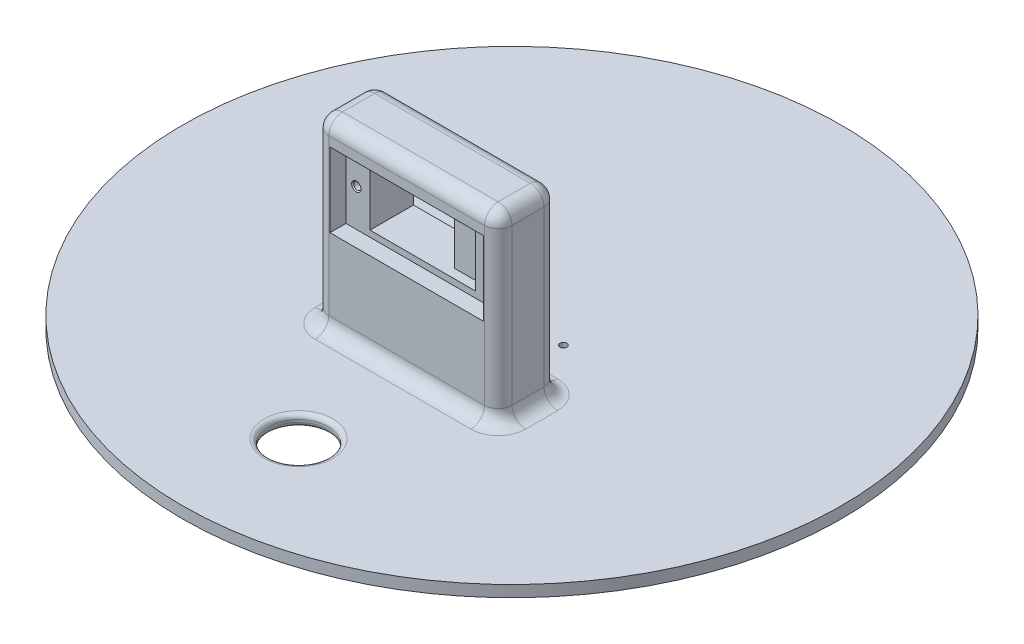
from build123d import *

# Parameters (mm, degrees)
SKETCH1_R                       = 72
BOSS_EXTRUDE1_DEPTH             = 2.5
SKETCH2_R                       = 0.75
CUT_EXTRUDE1_DEPTH              = 2.5
SKETCH5_W                       = 40
SKETCH5_H                       = 18
BOSS_EXTRUDE3_DEPTH             = 40
SKETCH6_W                       = 33.5
SKETCH6_H                       = 16.220064856
CUT_EXTRUDE2_DEPTH              = 3.5
SKETCH7_W                       = 23
SKETCH7_H                       = 16.220064856
CUT_EXTRUDE3_DEPTH              = 2
SKETCH8_W                       = 16.5
SKETCH8_H                       = 16.220064856
CUT_EXTRUDE4_DEPTH              = 7
SKETCH9_W                       = 5
SKETCH9_H                       = 40
CUT_EXTRUDE5_DEPTH              = 93
SKETCH10_W                      = 16.5
SKETCH10_H                      = 16.220064856
CUT_EXTRUDE6_DEPTH              = 83.5
SKETCH13_W                      = 33.5
SKETCH13_H                      = 1.36
BOSS_EXTRUDE4_DEPTH             = 9.5
M2X0_4_TAPPED_HOLE1_D           = 1.6
M2X0_4_TAPPED_HOLE1_DEPTH       = 6
M2X0_4_TAPPED_HOLE1_CSINK_D     = 2.05
M2X0_4_TAPPED_HOLE1_CSINK_ANGLE = 90
M2X0_4_TAPPED_HOLE1_TIP         = 0.480688495
FILLET1_R                       = 3
FILLET2_R                       = 3
FILLET3_R                       = 3
SKETCH16_R                      = 6.5
CUT_EXTRUDE7_DEPTH              = 3.5
FILLET4_R                       = 1
SKETCH17_R                      = 0.75
CUT_EXTRUDE8_DEPTH              = 3.5


with BuildPart() as part:
    # Sketch1 → Boss-Extrude1 (new body)
    with BuildSketch(Plane(origin=(0, 0, 0), x_dir=(1, 0, 0), z_dir=(0, 1, 0))):
        Circle(SKETCH1_R)
    extrude(amount=BOSS_EXTRUDE1_DEPTH)

    # Sketch2 → Cut-Extrude1 (cut)
    with BuildSketch(Plane(origin=(0, 0, 0), x_dir=(-1, 0, 0), z_dir=(0, -1, 0))):
        with Locations((-11.25, 0)):
            Circle(SKETCH2_R)
        with Locations((11.25, 0)):
            Circle(SKETCH2_R)
    extrude(amount=-CUT_EXTRUDE1_DEPTH, mode=Mode.SUBTRACT)

    # Sketch5 → Boss-Extrude3 (add)
    with BuildSketch(Plane(origin=(0, 2.5, 0), x_dir=(1, 0, 0), z_dir=(0, 1, 0))):
        with Locations((0, -14)):
            Rectangle(SKETCH5_W, SKETCH5_H)
    extrude(amount=BOSS_EXTRUDE3_DEPTH)

    # Sketch6 → Cut-Extrude2 (cut)
    with BuildSketch(Plane.XY.offset(23)):
        with Locations((0, 29.389629851)):
            Rectangle(SKETCH6_W, SKETCH6_H)
    extrude(amount=-CUT_EXTRUDE2_DEPTH, mode=Mode.SUBTRACT)

    # Sketch7 → Cut-Extrude3 (cut)
    with BuildSketch(Plane.XY.offset(19.5)):
        with Locations((0, 29.389629851)):
            Rectangle(SKETCH7_W, SKETCH7_H)
    extrude(amount=-CUT_EXTRUDE3_DEPTH, mode=Mode.SUBTRACT)

    # Sketch8 → Cut-Extrude4 (cut)
    with BuildSketch(Plane.XY.offset(17.5)):
        with Locations((-3.25, 29.389629851)):
            Rectangle(SKETCH8_W, SKETCH8_H)
    extrude(amount=-CUT_EXTRUDE4_DEPTH, mode=Mode.SUBTRACT)

    # Sketch9 → Cut-Extrude5 (cut, through all)
    with BuildSketch(Plane(origin=(20, 0, 0), x_dir=(0, 0, -1), z_dir=(1, 0, 0))):
        with Locations((-7.5, 22.5)):
            Rectangle(SKETCH9_W, SKETCH9_H)
    extrude(amount=-CUT_EXTRUDE5_DEPTH, mode=Mode.SUBTRACT)

    # Sketch10 → Cut-Extrude6 (cut, through all)
    with BuildSketch(Plane.XY.offset(10.5)):
        with Locations((-3.25, 29.389629851)):
            Rectangle(SKETCH10_W, SKETCH10_H)
    extrude(amount=-CUT_EXTRUDE6_DEPTH, mode=Mode.SUBTRACT)

    # Sketch13 → Boss-Extrude4 (add)
    with BuildSketch(Plane.XY.offset(19.5)):
        with Locations((0, 36.819662279)):
            Rectangle(SKETCH13_W, SKETCH13_H)
        with Locations((0, 21.959597423)):
            Rectangle(SKETCH13_W, SKETCH13_H)
    extrude(amount=-BOSS_EXTRUDE4_DEPTH)

    # M2x0.4 Tapped Hole1
    with Locations(Plane.XY.offset(19.5)):
        with Locations((14.5, 29.389662279), (-14.5, 29.389662279)):
            CounterSinkHole(M2X0_4_TAPPED_HOLE1_D / 2, M2X0_4_TAPPED_HOLE1_CSINK_D / 2, depth=M2X0_4_TAPPED_HOLE1_DEPTH, counter_sink_angle=M2X0_4_TAPPED_HOLE1_CSINK_ANGLE)
            with Locations((0, 0, -(M2X0_4_TAPPED_HOLE1_DEPTH + M2X0_4_TAPPED_HOLE1_TIP / 2))):  # 118° drill point
                Cone(0, M2X0_4_TAPPED_HOLE1_D / 2, M2X0_4_TAPPED_HOLE1_TIP, mode=Mode.SUBTRACT)

    # Fillet1
    fillet1_edges = [part.edges().sort_by_distance(p)[0] for p in [
        (-20, 22.5, 23),
        (20, 22.5, 23),
        (-20, 22.5, 10),
        (20, 22.5, 10),
    ]]
    fillet(fillet1_edges, radius=FILLET1_R)

    # Fillet2
    fillet2_edges = [part.edges().sort_by_distance(p)[0] for p in [
        (20, 2.5, 16.5),
        (0, 2.5, 23),
        (-20, 2.5, 16.5),
        (0, 2.5, 10),
        (19.121320344, 2.5, 22.121320344),
        (-19.121320344, 2.5, 22.121320344),
        (-19.121320344, 2.5, 10.878679656),
        (19.121320344, 2.5, 10.878679656),
    ]]
    fillet(fillet2_edges, radius=FILLET2_R)

    # Fillet3
    fillet3_edges = [part.edges().sort_by_distance(p)[0] for p in [
        (20, 42.5, 16.5),
        (0, 42.5, 23),
        (0, 42.5, 10),
        (-20, 42.5, 16.5),
        (19.121320344, 42.5, 10.878679656),
        (-19.121320344, 42.5, 10.878679656),
        (-19.121320344, 42.5, 22.121320344),
        (19.121320344, 42.5, 22.121320344),
    ]]
    fillet(fillet3_edges, radius=FILLET3_R)

    # Sketch16 → Cut-Extrude7 (cut, through all)
    with BuildSketch(Plane(origin=(0, 2.5, 0), x_dir=(1, 0, 0), z_dir=(0, 1, 0))):
        with Locations((0, -46.614420622)):
            Circle(SKETCH16_R)
    extrude(amount=-CUT_EXTRUDE7_DEPTH, mode=Mode.SUBTRACT)

    # Fillet4
    fillet4_edges = [part.edges().sort_by_distance(p)[0] for p in [
        (-6.5, 0, 46.614420622),
        (-6.5, 2.5, 46.614420622),
    ]]
    fillet(fillet4_edges, radius=FILLET4_R)

    # Sketch17 → Cut-Extrude8 (cut, through all)
    with BuildSketch(Plane(origin=(0, 2.5, 0), x_dir=(1, 0, 0), z_dir=(0, 1, 0))):
        with Locations((4.75, 0)):
            Circle(SKETCH17_R)
        with Locations((-4.75, 0)):
            Circle(SKETCH17_R)
    extrude(amount=-CUT_EXTRUDE8_DEPTH, mode=Mode.SUBTRACT)


solid = part.part
